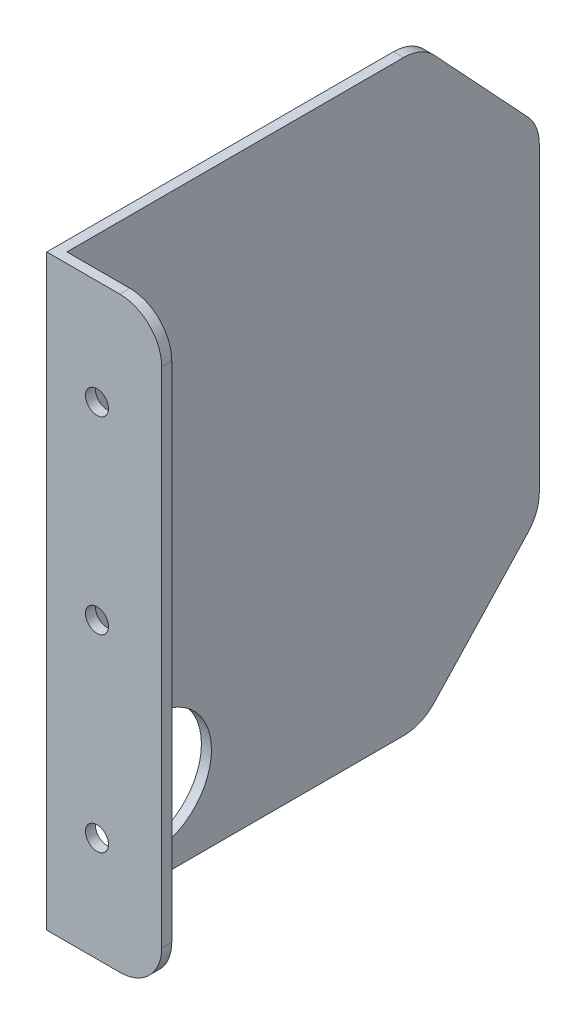
from build123d import *

# Parameters (mm, degrees)
SKETCH1_W           = 115
SKETCH1_H           = 140
BOSS_EXTRUDE1_DEPTH = 2.4
CUT_EXTRUDE1_DEPTH  = 3.4
FILLET1_R           = 10
SKETCH3_W           = 2.4
SKETCH3_H           = 140
BOSS_EXTRUDE2_DEPTH = 25
FILLET2_R           = 10
SKETCH4_R           = 2.75
CUT_EXTRUDE2_DEPTH  = 116
SKETCH5_R           = 14.275
CUT_EXTRUDE3_DEPTH  = 3.4


with BuildPart() as part:
    # Sketch1 → Boss-Extrude1 (new body)
    with BuildSketch(Plane(origin=(0, 0, 0), x_dir=(0, 0, -1), z_dir=(1, 0, 0))):
        with Locations((57.5, -70)):
            Rectangle(SKETCH1_W, SKETCH1_H)
    extrude(amount=BOSS_EXTRUDE1_DEPTH)

    # Sketch2 → Cut-Extrude1 (cut, through all)
    with BuildSketch(Plane(origin=(2.4, 0, 0), x_dir=(0, 0, -1), z_dir=(1, 0, 0))):
        Polygon((87, 0), (115, -30), (142.616199658, -32.505405645), (142.616199658, 14.875556406), align=None)
        Polygon((115, -110), (87, -140), (87, -152.661109726), (136.310004643, -152.661109726), align=None)
    extrude(amount=-CUT_EXTRUDE1_DEPTH, mode=Mode.SUBTRACT)

    # Fillet1
    fillet1_edges = [part.edges().sort_by_distance(p)[0] for p in [
        (1.2, 0, -87),
        (1.2, -30, -115),
        (1.2, -110, -115),
        (1.2, -140, -87),
    ]]
    fillet(fillet1_edges, radius=FILLET1_R)

    # Sketch3 → Boss-Extrude2 (add)
    with BuildSketch(Plane(origin=(2.4, 0, 0), x_dir=(0, 0, -1), z_dir=(1, 0, 0))):
        with Locations((1.2, -70)):
            Rectangle(SKETCH3_W, SKETCH3_H)
    extrude(amount=BOSS_EXTRUDE2_DEPTH)

    # Fillet2
    fillet2_edges = [part.edges().sort_by_distance(p)[0] for p in [
        (27.4, -140, -1.2),
        (27.4, 0, -1.2),
    ]]
    fillet(fillet2_edges, radius=FILLET2_R)

    # Sketch4 → Cut-Extrude2 (cut, through all)
    with BuildSketch(Plane.XY):
        with Locations((11.974983581, -70)):
            Circle(SKETCH4_R)
        with Locations((11.974983581, -25)):
            Circle(SKETCH4_R)
        with Locations((11.974983581, -115)):
            Circle(SKETCH4_R)
    extrude(amount=-CUT_EXTRUDE2_DEPTH, mode=Mode.SUBTRACT)

    # Sketch5 → Cut-Extrude3 (cut, through all)
    with BuildSketch(Plane(origin=(2.4, 0, 0), x_dir=(0, 0, -1), z_dir=(1, 0, 0))):
        with Locations((22.591699334, -120)):
            Circle(SKETCH5_R)
    extrude(amount=-CUT_EXTRUDE3_DEPTH, mode=Mode.SUBTRACT)


solid = part.part
